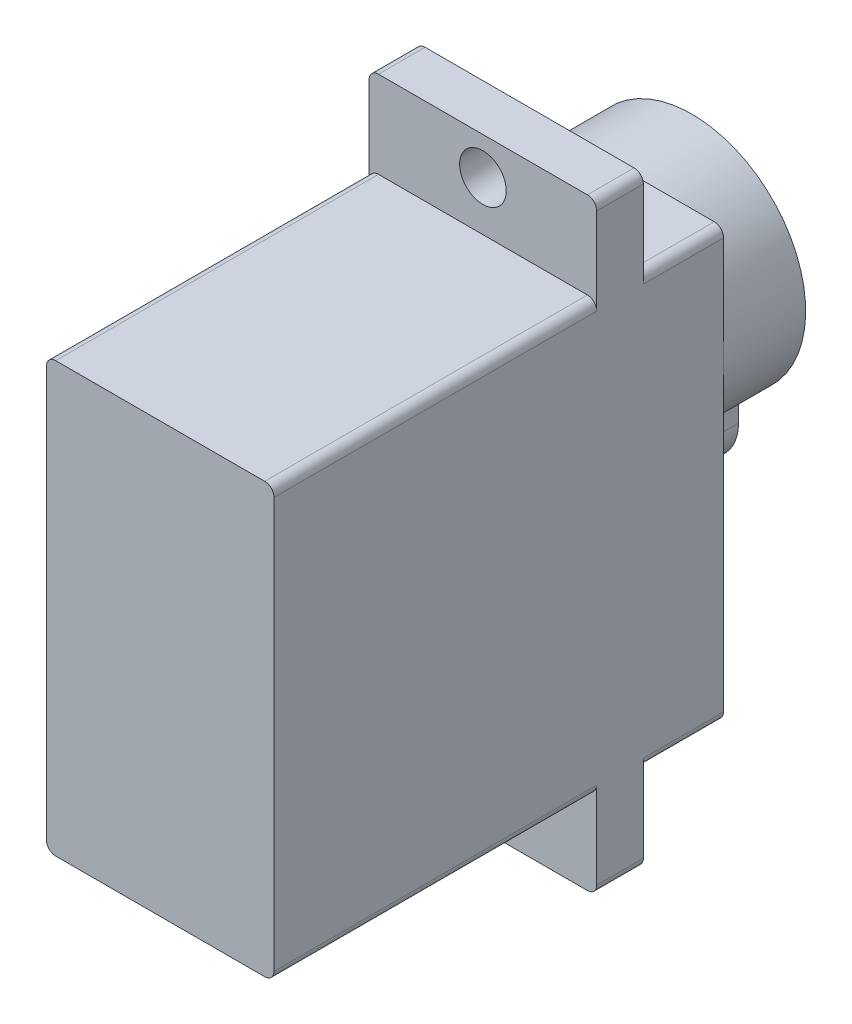
from build123d import *

# Parameters (mm, degrees)
BOSS_EXTRUDE1_DEPTH = 12.05
SKETCH2_R           = 1.25
BOSS_EXTRUDE2_DEPTH = 2.5
BOSS_EXTRUDE3_DEPTH = 4.4
SKETCH4_R           = 0.5
BOSS_EXTRUDE4_DEPTH = 3.7
CHAMFER1_SIZE       = 0.1


with BuildPart() as part:
    # Sketch1 → Boss-Extrude1 (new body, symmetric)
    with BuildSketch(Plane.XY):
        with BuildLine():
            Line((-5.6, -11.5), (5.6, -11.5))
            ThreePointArc((5.6, -11.5), (5.953553391, -11.353553391), (6.1, -11))
            Line((6.1, -11), (6.1, 11))
            ThreePointArc((6.1, 11), (5.953553391, 11.353553391), (5.6, 11.5))
            Line((5.6, 11.5), (-5.6, 11.5))
            ThreePointArc((-5.6, 11.5), (-5.953553391, 11.353553391), (-6.1, 11))
            Line((-6.1, 11), (-6.1, -11))
            ThreePointArc((-6.1, -11), (-5.953553391, -11.353553391), (-5.6, -11.5))
        make_face()
    extrude(amount=BOSS_EXTRUDE1_DEPTH, both=True)

    # Sketch2 → Boss-Extrude2 (add)
    with BuildSketch(Plane.XY.offset(-7.75)):
        with BuildLine():
            Line((6.1, 11), (6.1, 15.65))
            ThreePointArc((6.1, 15.65), (5.953553391, 16.003553391), (5.6, 16.15))
            Line((5.6, 16.15), (-5.6, 16.15))
            ThreePointArc((-5.6, 16.15), (-5.953553391, 16.003553391), (-6.1, 15.65))
            Line((-6.1, 15.65), (-6.1, 11))
            ThreePointArc((-6.1, 11), (-5.953553391, 11.353553391), (-5.6, 11.5))
            Line((-5.6, 11.5), (5.6, 11.5))
            ThreePointArc((5.6, 11.5), (5.953553391, 11.353553391), (6.1, 11))
        make_face()
        with Locations((0, 14.15)):
            Circle(SKETCH2_R, mode=Mode.SUBTRACT)
        with BuildLine():
            Line((5.6, -11.5), (-5.6, -11.5))
            ThreePointArc((-5.6, -11.5), (-5.953553391, -11.353553391), (-6.1, -11))
            Line((-6.1, -11), (-6.1, -15.65))
            ThreePointArc((-6.1, -15.65), (-5.953553391, -16.003553391), (-5.6, -16.15))
            Line((-5.6, -16.15), (5.6, -16.15))
            ThreePointArc((5.6, -16.15), (5.953553391, -16.003553391), (6.1, -15.65))
            Line((6.1, -15.65), (6.1, -11))
            ThreePointArc((6.1, -11), (5.953553391, -11.353553391), (5.6, -11.5))
        make_face()
        with Locations((0, -14.15)):
            Circle(SKETCH2_R, mode=Mode.SUBTRACT)
    extrude(amount=BOSS_EXTRUDE2_DEPTH)

    # Sketch3 → Boss-Extrude3 (add)
    with BuildSketch(Plane(origin=(0, 0, -12.05), x_dir=(-1, 0, 0), z_dir=(0, 0, -1))):
        with BuildLine():
            Line((-2.5, -1.6), (-2.5, -0.164171097))
            ThreePointArc((-2.5, -0.164171097), (0, 11.5), (2.5, -0.164171097))
            Line((2.5, -0.164171097), (2.5, -1.6))
            ThreePointArc((2.5, -1.6), (0, -4.1), (-2.5, -1.6))
        make_face()
    extrude(amount=BOSS_EXTRUDE3_DEPTH)

    # Sketch4 → Boss-Extrude4 (add)
    with BuildSketch(Plane(origin=(0, 0, -16.45), x_dir=(-1, 0, 0), z_dir=(0, 0, -1))):
        with Locations((0, 5.4)):
            Circle(SKETCH4_R)
    extrude(amount=BOSS_EXTRUDE4_DEPTH)

    # Chamfer1
    chamfer1_edges = [part.edges().sort_by_distance(p)[0] for p in [
        (0.5, 5.4, -20.15),
    ]]
    chamfer(chamfer1_edges, length=CHAMFER1_SIZE)


solid = part.part
